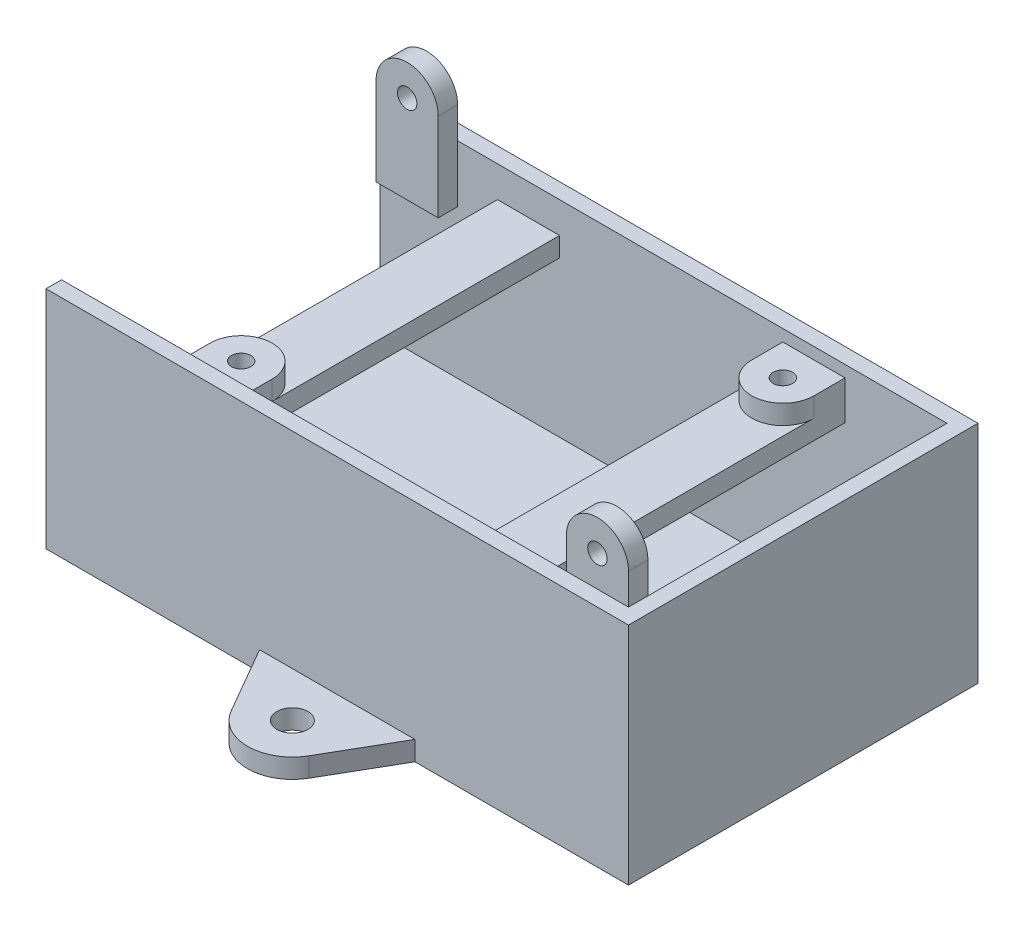
from build123d import *

# Parameters (mm, degrees)
SKETCH1_W           = 75
SKETCH1_H           = 45
BOSS_EXTRUDE1_DEPTH = 2.5
SKETCH2_W           = 75
SKETCH2_H           = 45
SKETCH2_W_2         = 71
SKETCH2_H_2         = 41
BOSS_EXTRUDE2_DEPTH = 20
SKETCH4_W           = 41
SKETCH4_H           = 20
CUT_EXTRUDE1_DEPTH  = 2
SKETCH5_W           = 8
SKETCH5_H           = 45
BOSS_EXTRUDE4_DEPTH = 2.5
BOSS_EXTRUDE5_DEPTH = 6.5
BOSS_EXTRUDE6_DEPTH = 2.5
SKETCH9_R           = 1.25
CUT_EXTRUDE2_DEPTH  = 5
BOSS_EXTRUDE7_DEPTH = 2.5
BOSS_EXTRUDE8_DEPTH = 2.5
SKETCH14_R          = 1.25
CUT_EXTRUDE3_DEPTH  = 2.5
SKETCH15_R          = 1.25
CUT_EXTRUDE4_DEPTH  = 2.5
BOSS_EXTRUDE9_DEPTH = 2.5
SKETCH20_R          = 2
CUT_EXTRUDE6_DEPTH  = 2.5


with BuildPart() as part:
    # Sketch1 → Boss-Extrude1 (new body)
    with BuildSketch(Plane(origin=(0, 0, 0), x_dir=(1, 0, 0), z_dir=(0, 1, 0))):
        Rectangle(SKETCH1_W, SKETCH1_H)
    extrude(amount=BOSS_EXTRUDE1_DEPTH)

    # Sketch2 → Boss-Extrude2 (add)
    with BuildSketch(Plane(origin=(0, 2.5, 0), x_dir=(1, 0, 0), z_dir=(0, 1, 0))):
        Rectangle(SKETCH2_W, SKETCH2_H)
        Rectangle(SKETCH2_W_2, SKETCH2_H_2, mode=Mode.SUBTRACT)
    extrude(amount=BOSS_EXTRUDE2_DEPTH)

    # Sketch4 → Cut-Extrude1 (cut)
    with BuildSketch(Plane.ZY.offset(37.5)):
        with Locations((0, 12.5)):
            Rectangle(SKETCH4_W, SKETCH4_H)
    extrude(amount=-CUT_EXTRUDE1_DEPTH, mode=Mode.SUBTRACT)

    # Sketch5 → Boss-Extrude4 (add)
    with BuildSketch(Plane(origin=(0, 22.5, 0), x_dir=(1, 0, 0), z_dir=(0, 1, 0))):
        with Locations((-18.375, 0)):
            Rectangle(SKETCH5_W, SKETCH5_H)
        with Locations((18.375, 0)):
            Rectangle(SKETCH5_W, SKETCH5_H)
    extrude(amount=BOSS_EXTRUDE4_DEPTH)

    # Sketch7 → Boss-Extrude5 (add)
    with BuildSketch(Plane(origin=(0, 22.5, 0), x_dir=(1, 0, 0), z_dir=(0, 1, 0))):
        Polygon((-37.5, 22.5), (37.5, 22.5), (37.5, -22.5), (-37.5, -22.5), (-37.5, -20.5), (35.5, -20.5), (35.5, 20.5), (-37.5, 20.5), align=None)
    extrude(amount=BOSS_EXTRUDE5_DEPTH)

    # Sketch8 → Boss-Extrude6 (add)
    with BuildSketch(Plane(origin=(0, 25, 0), x_dir=(1, 0, 0), z_dir=(0, 1, 0))):
        with BuildLine():
            Line((-22.375, -20.5), (-14.375, -20.5))
            Line((-14.375, -20.5), (-14.375, -16.5))
            ThreePointArc((-14.375, -16.5), (-18.375, -12.5), (-22.375, -16.5))
            Line((-22.375, -16.5), (-22.375, -20.5))
        make_face()
        with BuildLine():
            Line((14.375, 16.5), (14.375, 20.5))
            Line((14.375, 20.5), (22.375, 20.5))
            Line((22.375, 20.5), (22.375, 16.5))
            ThreePointArc((22.375, 16.5), (18.375, 12.5), (14.375, 16.5))
        make_face()
    extrude(amount=BOSS_EXTRUDE6_DEPTH)

    # Sketch9 → Cut-Extrude2 (cut)
    with BuildSketch(Plane(origin=(0, 27.5, 0), x_dir=(1, 0, 0), z_dir=(0, 1, 0))):
        with Locations((-18.375, -16.5)):
            Circle(SKETCH9_R)
        with Locations((18.375, 16.5)):
            Circle(SKETCH9_R)
    extrude(amount=-CUT_EXTRUDE2_DEPTH, mode=Mode.SUBTRACT)

    # Sketch12 → Boss-Extrude7 (add)
    with BuildSketch(Plane(origin=(0, 0, 20.5), x_dir=(-1, 0, 0), z_dir=(0, 0, -1))):
        with BuildLine():
            Line((-35.5, 22.5), (-27.5, 22.5))
            Line((-27.5, 22.5), (-27.5, 29))
            Line((-27.5, 29), (-27.5, 33))
            ThreePointArc((-27.5, 33), (-31.5, 37), (-35.5, 33))
            Line((-35.5, 33), (-35.5, 22.5))
        make_face()
    extrude(amount=BOSS_EXTRUDE7_DEPTH)

    # Sketch13 → Boss-Extrude8 (add)
    with BuildSketch(Plane.XY.offset(-20.5)):
        with BuildLine():
            Line((-35.5, 29), (-35.5, 21.654961558))
            Line((-35.5, 21.654961558), (-27.5, 21.654961558))
            Line((-27.5, 21.654961558), (-27.5, 29))
            Line((-27.5, 29), (-27.5, 33))
            ThreePointArc((-27.5, 33), (-31.5, 37), (-35.5, 33))
            Line((-35.5, 33), (-35.5, 29))
        make_face()
    extrude(amount=BOSS_EXTRUDE8_DEPTH)

    # Sketch14 → Cut-Extrude3 (cut)
    with BuildSketch(Plane(origin=(0, 0, -20.5), x_dir=(-1, 0, 0), z_dir=(0, 0, -1))):
        with Locations((31.5, 33)):
            Circle(SKETCH14_R)
    extrude(amount=-CUT_EXTRUDE3_DEPTH, mode=Mode.SUBTRACT)

    # Sketch15 → Cut-Extrude4 (cut)
    with BuildSketch(Plane(origin=(0, 0, 18), x_dir=(-1, 0, 0), z_dir=(0, 0, -1))):
        with Locations((-31.5, 33)):
            Circle(SKETCH15_R)
    extrude(amount=-CUT_EXTRUDE4_DEPTH, mode=Mode.SUBTRACT)


with BuildPart() as body_2:
    # Sketch16 → Boss-Extrude9 (new body)
    with BuildSketch(Plane(origin=(0, 0, 0), x_dir=(-1, 0, 0), z_dir=(0, -1, 0))):
        with BuildLine():
            Line((-10, -22.5), (10, -22.5))
            Line((10, -22.5), (5, -31.160254038))
            ThreePointArc((5, -31.160254038), (0, -34.047005384), (-5, -31.160254038))
            Line((-5, -31.160254038), (-10, -22.5))
        make_face()
    extrude(amount=-BOSS_EXTRUDE9_DEPTH)

    # Sketch20 → Cut-Extrude6 (cut)
    with BuildSketch(Plane.XZ):
        with Locations((0, 28.273502692)):
            Circle(SKETCH20_R)
    extrude(amount=-CUT_EXTRUDE6_DEPTH, mode=Mode.SUBTRACT)


with BuildPart() as body_3:
    # Mirror2: mirrored copy
    add(body_2.part.mirror(Plane.XY))


solid = Compound([part.part, body_2.part, body_3.part])
